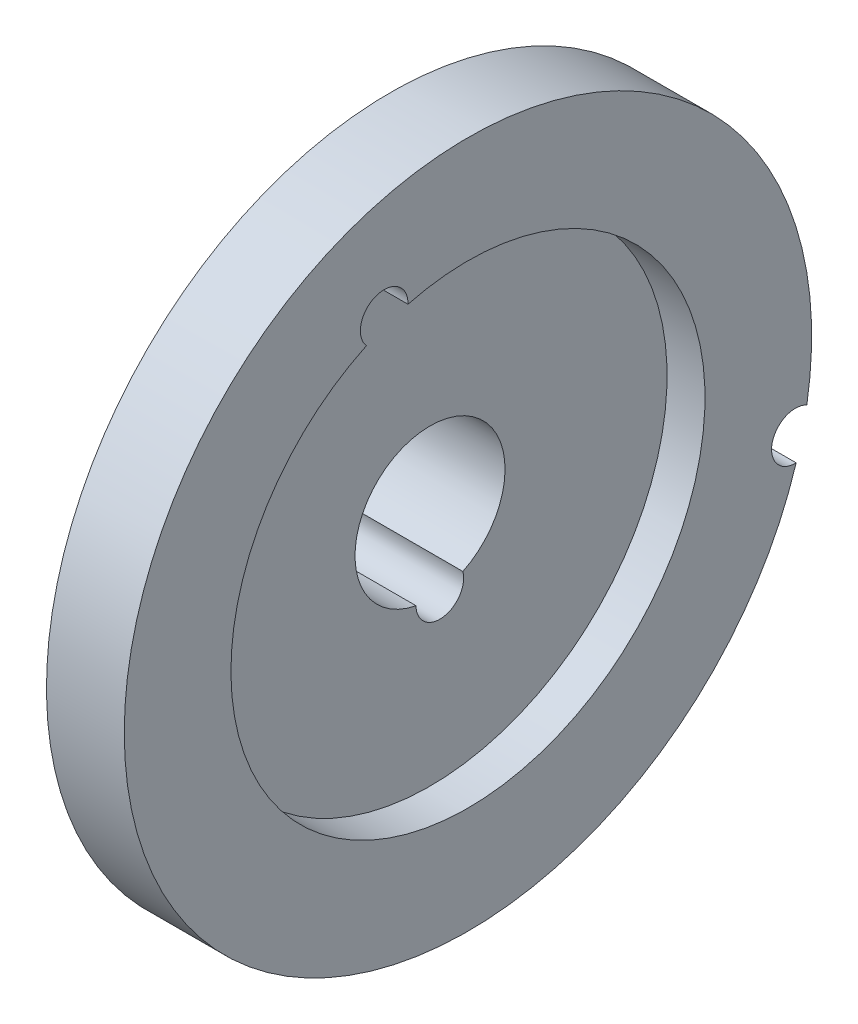
from build123d import *

# Parameters (mm, degrees)
SKETCH2_R          = 2.5527
CUT_EXTRUDE1_DEPTH = 18.897183893


with BuildPart() as part:
    # Sketch1 → Revolve1 (revolve)
    with BuildSketch(Plane.XY):
        Polygon((-27.857278892, 8.0391), (-14.024094998, 8.0391), (-14.024094998, 25.4), (-9.960094998, 25.4), (-9.960094998, 36.83), (-18.295757287, 36.83), (-27.857278892, 17.801339222), align=None)
    revolve(axis=Axis((0, 0, 0), (-1, 0, 0)))

    # Sketch2 → Cut-Extrude1 (cut, through all)
    with BuildSketch(Plane(origin=(-9.960094998, 0, 0), x_dir=(0, 0, -1), z_dir=(1, 0, 0))):
        with Locations((35.086604814, -8.389036369)):
            Circle(SKETCH2_R)
        with Locations((1.050672613, -7.874611544)):
            Circle(SKETCH2_R)
        with Locations((18.860257121, 44.244090147)):
            Circle(SKETCH2_R)
        with Locations((46.093533365, 23.822092726)):
            Circle(SKETCH2_R)
        with Locations((-8.977761775, 24.654449577)):
            Circle(SKETCH2_R)
    extrude(amount=-CUT_EXTRUDE1_DEPTH, mode=Mode.SUBTRACT)


solid = part.part
